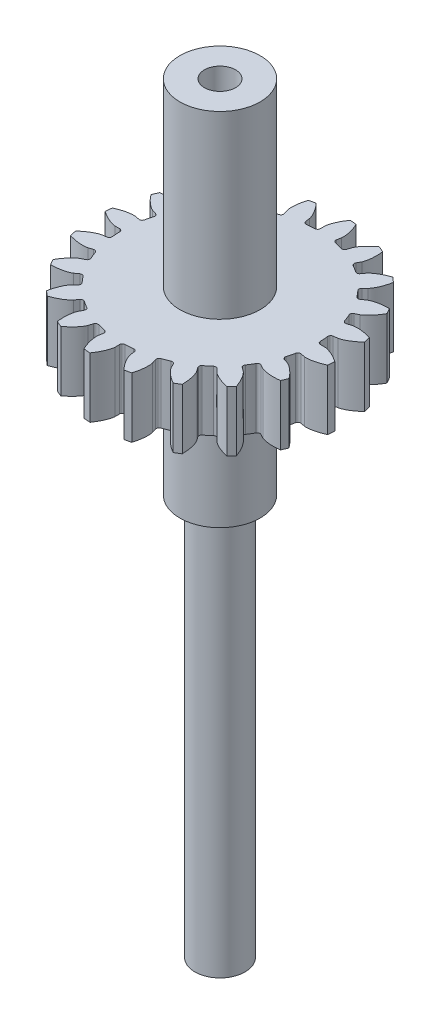
from build123d import *

# Parameters (mm, degrees)
SKETCH1_R            = 2.5
BEARINGSECTION_DEPTH = 2.5
SKETCH2_R            = 4
BOSS_EXTRUDE2_DEPTH  = 12
BOSS_EXTRUDE3_DEPTH  = 6
SKETCH7_R            = 4
BOSS_EXTRUDE4_DEPTH  = 17.95
SKETCH8_R            = 1.55
CUT_EXTRUDE1_DEPTH   = 18.95
SKETCH9_R            = 2.5
BOSS_EXTRUDE5_DEPTH  = 34.95
SKETCH10_R           = 1.55
CUT_EXTRUDE2_DEPTH   = 17


with BuildPart() as part:
    # Sketch1 → BearingSection (new body, symmetric)
    with BuildSketch(Plane(origin=(0, 0, 0), x_dir=(1, 0, 0), z_dir=(0, 1, 0))):
        Circle(SKETCH1_R)
    extrude(amount=BEARINGSECTION_DEPTH, both=True)

    # Sketch2 → Boss-Extrude2 (add)
    with BuildSketch(Plane(origin=(0, 2.5, 0), x_dir=(1, 0, 0), z_dir=(0, 1, 0))):
        Circle(SKETCH2_R)
    extrude(amount=BOSS_EXTRUDE2_DEPTH)

    # GearSketch → Boss-Extrude3 (add)
    with BuildSketch(Plane(origin=(0, 14.5, 0), x_dir=(1, 0, 0), z_dir=(0, 1, 0))):
        with BuildLine():
            Line((-9.850675874, 1.771154304), (-10.289089687, 1.849981232))
            add(Edge.make_bspline(
                [(-10.289089687, 1.849981232), (-10.296725387, 1.851187956), (-10.318214598, 1.854071384), (-10.359105487, 1.857540428), (-10.426058487, 1.860369506), (-10.511594622, 1.8598097), (-10.622203614, 1.854298135), (-10.752376809, 1.841657203), (-10.89505139, 1.821337826), (-11.049607754, 1.792328646), (-11.203014554, 1.757310247), (-11.355131771, 1.716760623), (-11.505723573, 1.671321215), (-11.686834397, 1.610374754), (-11.868284774, 1.541863752), (-12.011218437, 1.481845381), (-12.116563281, 1.434584042), (-12.155203392, 1.416840409)],
                knots=[0, 0, 0, 0, 0, 0.005376748, 0.015083688, 0.02853182, 0.046610139, 0.064854849, 0.092110525, 0.119476175, 0.146842495, 0.174208853, 0.201574955, 0.228941013, 0.256307345, 0.307035032, 0.336624535, 0.336624535, 0.336624535, 0.336624535, 0.336624535], degree=4))
            ThreePointArc((-12.155203392, 1.416840409), (-12.189120016, 1.087087613), (-12.21409259, 0.756537141))
            add(Edge.make_bspline(
                [(-12.21409259, 0.756537141), (-12.179202273, 0.732235691), (-12.083883515, 0.667078153), (-11.953826699, 0.582713105), (-11.787363934, 0.483173443), (-11.619896721, 0.391139023), (-11.479722698, 0.319767641), (-11.337182026, 0.252938931), (-11.192393304, 0.191325941), (-11.045409754, 0.135423901), (-10.908582693, 0.090177148), (-10.782700919, 0.054699934), (-10.674812946, 0.0297017), (-10.590725843, 0.014014033), (-10.524328883, 0.004950284), (-10.48346946, 0.00112842), (-10.461809141, 0.000163554), (-10.454080406, 0)],
                knots=[0, 0, 0, 0, 0, 0.029589503, 0.08031719, 0.107683522, 0.13504958, 0.162415682, 0.18978204, 0.21714836, 0.24451401, 0.271769686, 0.290014396, 0.308092715, 0.321540847, 0.331247787, 0.336624535, 0.336624535, 0.336624535, 0.336624535, 0.336624535], degree=4))
            Line((-10.454080406, 0), (-10.008636407, 0))
            ThreePointArc((-10.008636407, 0), (-9.814723016, -0.07874819), (-9.730618729, -0.270399306))
            ThreePointArc((-9.730618729, -0.270399306), (-9.7117918, -0.662688973), (-9.677156173, -1.053899925))
            ThreePointArc((-9.677156173, -1.053899925), (-9.734447291, -1.255199227), (-9.915866259, -1.359558409))
            Line((-9.915866259, -1.359558409), (-10.357181433, -1.420066864))
            add(Edge.make_bspline(
                [(-10.357181433, -1.420066864), (-10.364816314, -1.421278762), (-10.386144797, -1.425176991), (-10.426106336, -1.434513714), (-10.490656656, -1.452512715), (-10.571833365, -1.479477242), (-10.675325601, -1.51889911), (-10.795221403, -1.57114708), (-10.92463396, -1.634560827), (-11.062661468, -1.709910739), (-11.197738724, -1.790620524), (-11.329880272, -1.876192313), (-11.459060037, -1.965943185), (-11.612473175, -2.079873036), (-11.763871674, -2.201102121), (-11.881262969, -2.302351914), (-11.966847312, -2.379853466), (-11.998113158, -2.408669115)],
                knots=[0, 0, 0, 0, 0, 0.005376748, 0.015083688, 0.02853182, 0.046610139, 0.064854849, 0.092110525, 0.119476175, 0.146842495, 0.174208853, 0.201574955, 0.228941013, 0.256307345, 0.307035032, 0.336624535, 0.336624535, 0.336624535, 0.336624535, 0.336624535], degree=4))
            ThreePointArc((-11.998113158, -2.408669115), (-11.928470566, -2.732763473), (-11.850075182, -3.054852604))
            add(Edge.make_bspline(
                [(-11.850075182, -3.054852604), (-11.809382957, -3.067182954), (-11.698594645, -3.09969634), (-11.548833029, -3.139742502), (-11.359758084, -3.182970523), (-11.172047101, -3.218750243), (-11.016678713, -3.243312305), (-10.860463271, -3.262822696), (-10.703721552, -3.276677955), (-10.546657208, -3.28442354), (-10.402544925, -3.285173872), (-10.271861181, -3.280015101), (-10.161528742, -3.270450617), (-10.076709399, -3.259386131), (-10.010761285, -3.247488479), (-9.970720645, -3.238497032), (-9.949822297, -3.232721268), (-9.942421292, -3.230488506)],
                knots=[0, 0, 0, 0, 0, 0.029589503, 0.08031719, 0.107683522, 0.13504958, 0.162415682, 0.18978204, 0.21714836, 0.24451401, 0.271769686, 0.290014396, 0.308092715, 0.321540847, 0.331247787, 0.336624535, 0.336624535, 0.336624535, 0.336624535, 0.336624535], degree=4))
            Line((-9.942421292, -3.230488506), (-9.518778874, -3.09283874))
            ThreePointArc((-9.518778874, -3.09283874), (-9.310021751, -3.107810187), (-9.170810369, -3.264091575))
            ThreePointArc((-9.170810369, -3.264091575), (-9.031680722, -3.631363378), (-8.87784945, -3.992724106))
            ThreePointArc((-8.87784945, -3.992724106), (-8.870131636, -4.201875048), (-9.010422567, -4.357188072))
            Line((-9.010422567, -4.357188072), (-9.411440098, -4.551108922))
            add(Edge.make_bspline(
                [(-9.411440098, -4.551108922), (-9.418326804, -4.554620813), (-9.437406778, -4.564919113), (-9.472527255, -4.586147658), (-9.52835626, -4.623212872), (-9.597227401, -4.673942643), (-9.683472338, -4.743415927), (-9.781354512, -4.83015654), (-9.884837242, -4.930457276), (-9.992824799, -5.044772147), (-10.096350209, -5.163272882), (-10.195581152, -5.285490473), (-10.290703865, -5.410767368), (-10.401402169, -5.566528362), (-10.507928851, -5.728608782), (-10.5882867, -5.861178963), (-10.64573295, -5.961334335), (-10.666564012, -5.998401323)],
                knots=[0, 0, 0, 0, 0, 0.005376748, 0.015083688, 0.02853182, 0.046610139, 0.064854849, 0.092110525, 0.119476175, 0.146842495, 0.174208853, 0.201574955, 0.228941013, 0.256307345, 0.307035032, 0.336624535, 0.336624535, 0.336624535, 0.336624535, 0.336624535], degree=4))
            ThreePointArc((-10.666564012, -5.998401323), (-10.500179306, -6.285112631), (-10.326089851, -6.567212091))
            add(Edge.make_bspline(
                [(-10.326089851, -6.567212091), (-10.283578957, -6.566364362), (-10.168165822, -6.563050958), (-10.013359117, -6.554858237), (-9.820179965, -6.537543157), (-9.63059967, -6.513565809), (-9.475245457, -6.488914246), (-9.320646701, -6.459196504), (-9.167294957, -6.423937784), (-9.015524373, -6.382768721), (-8.878233581, -6.338949185), (-8.755540103, -6.293659404), (-8.653563306, -6.25046844), (-8.576314431, -6.213734871), (-8.517270624, -6.182040443), (-8.481968222, -6.16111583), (-8.463877522, -6.149164808), (-8.457528709, -6.144754289)],
                knots=[0, 0, 0, 0, 0, 0.029589503, 0.08031719, 0.107683522, 0.13504958, 0.162415682, 0.18978204, 0.21714836, 0.24451401, 0.271769686, 0.290014396, 0.308092715, 0.321540847, 0.331247787, 0.336624535, 0.336624535, 0.336624535, 0.336624535, 0.336624535], degree=4))
            Line((-8.457528709, -6.144754289), (-8.097156944, -5.882928876))
            ThreePointArc((-8.097156944, -5.882928876), (-7.89399069, -5.832658068), (-7.713299194, -5.938271818))
            ThreePointArc((-7.713299194, -5.938271818), (-7.467485807, -6.244574634), (-7.209516967, -6.540712632))
            ThreePointArc((-7.209516967, -6.540712632), (-7.137545695, -6.737242062), (-7.222975935, -6.928305808))
            Line((-7.222975935, -6.928305808), (-7.544441433, -7.236656728))
            add(Edge.make_bspline(
                [(-7.544441433, -7.236656728), (-7.549905846, -7.242124844), (-7.564869629, -7.257815146), (-7.591711206, -7.288857516), (-7.633353964, -7.341360741), (-7.683177951, -7.410889973), (-7.743733335, -7.503614144), (-7.81002049, -7.616356625), (-7.877443783, -7.743726216), (-7.944820815, -7.885816109), (-8.00666059, -8.030508116), (-8.063267512, -8.177408), (-8.115021899, -8.325947942), (-8.172169448, -8.508293107), (-8.223396739, -8.695359302), (-8.258855156, -8.846272977), (-8.282540074, -8.959278265), (-8.290897262, -9.000968217)],
                knots=[0, 0, 0, 0, 0, 0.005376748, 0.015083688, 0.02853182, 0.046610139, 0.064854849, 0.092110525, 0.119476175, 0.146842495, 0.174208853, 0.201574955, 0.228941013, 0.256307345, 0.307035032, 0.336624535, 0.336624535, 0.336624535, 0.336624535, 0.336624535], degree=4))
            ThreePointArc((-8.290897262, -9.000968217), (-8.044057337, -9.222231173), (-7.791314899, -9.436727102))
            add(Edge.make_bspline(
                [(-7.791314899, -9.436727102), (-7.751146599, -9.422784276), (-7.642406083, -9.383968421), (-7.497707847, -9.328338778), (-7.31933421, -9.252175517), (-7.146442043, -9.170788171), (-7.006309158, -9.09933605), (-6.868460291, -9.023299154), (-6.73350966, -8.942377824), (-6.601889196, -8.856324029), (-6.484858876, -8.772223985), (-6.382165756, -8.691236474), (-6.2985268, -8.618646864), (-6.236410052, -8.559839948), (-6.190050171, -8.511451216), (-6.162941653, -8.480641684), (-6.149429443, -8.463685253), (-6.144754289, -8.457528709)],
                knots=[0, 0, 0, 0, 0, 0.029589503, 0.08031719, 0.107683522, 0.13504958, 0.162415682, 0.18978204, 0.21714836, 0.24451401, 0.271769686, 0.290014396, 0.308092715, 0.321540847, 0.331247787, 0.336624535, 0.336624535, 0.336624535, 0.336624535, 0.336624535], degree=4))
            Line((-6.144754289, -8.457528709), (-5.882928876, -8.097156944))
            ThreePointArc((-5.882928876, -8.097156944), (-5.70524082, -7.98656474), (-5.500756551, -8.031172642))
            ThreePointArc((-5.500756551, -8.031172642), (-5.172321352, -8.246523417), (-4.835466732, -8.448450634))
            ThreePointArc((-4.835466732, -8.448450634), (-4.706287051, -8.613120883), (-4.728494093, -8.8212327))
            Line((-4.728494093, -8.8212327), (-4.938940275, -9.213830153))
            add(Edge.make_bspline(
                [(-4.938940275, -9.213830153), (-4.9424475, -9.220719237), (-4.951830334, -9.240265664), (-4.96776557, -9.278083216), (-4.991145798, -9.34088507), (-5.017045511, -9.422407758), (-5.045983759, -9.529306328), (-5.074187247, -9.657014656), (-5.098951242, -9.798985279), (-5.119122415, -9.954941446), (-5.133223247, -10.111661263), (-5.141665068, -10.268863856), (-5.144985049, -10.426126721), (-5.142987842, -10.617206842), (-5.133901258, -10.810947469), (-5.120989326, -10.965432157), (-5.108594468, -11.080225614), (-5.103659722, -11.122457628)],
                knots=[0, 0, 0, 0, 0, 0.005376748, 0.015083688, 0.02853182, 0.046610139, 0.064854849, 0.092110525, 0.119476175, 0.146842495, 0.174208853, 0.201574955, 0.228941013, 0.256307345, 0.307035032, 0.336624535, 0.336624535, 0.336624535, 0.336624535, 0.336624535], degree=4))
            ThreePointArc((-5.103659722, -11.122457628), (-4.80052699, -11.256613473), (-4.493871759, -11.382509515))
            add(Edge.make_bspline(
                [(-4.493871759, -11.382509515), (-4.459978006, -11.356836412), (-4.368554389, -11.286317673), (-4.248128693, -11.188696524), (-4.102021026, -11.061140474), (-3.962740876, -10.93030989), (-3.851546503, -10.819051442), (-3.743941133, -10.704138414), (-3.640601522, -10.585475617), (-3.542015107, -10.462960635), (-3.456701001, -10.346812383), (-3.384060558, -10.238054763), (-3.326946607, -10.143172082), (-3.286042405, -10.068048251), (-3.256904479, -10.007701841), (-3.240643415, -9.970023242), (-3.233032365, -9.949721215), (-3.230488506, -9.942421292)],
                knots=[0, 0, 0, 0, 0, 0.029589503, 0.08031719, 0.107683522, 0.13504958, 0.162415682, 0.18978204, 0.21714836, 0.24451401, 0.271769686, 0.290014396, 0.308092715, 0.321540847, 0.331247787, 0.336624535, 0.336624535, 0.336624535, 0.336624535, 0.336624535], degree=4))
            Line((-3.230488506, -9.942421292), (-3.09283874, -9.518778874))
            ThreePointArc((-3.09283874, -9.518778874), (-2.958022227, -9.358690809), (-2.749761532, -9.337926331))
            ThreePointArc((-2.749761532, -9.337926331), (-2.370854046, -9.441245031), (-1.988087323, -9.529195424))
            ThreePointArc((-1.988087323, -9.529195424), (-1.81434424, -9.645887421), (-1.771154304, -9.850675874))
            Line((-1.771154304, -9.850675874), (-1.849981232, -10.289089687))
            add(Edge.make_bspline(
                [(-1.849981232, -10.289089687), (-1.851187956, -10.296725387), (-1.854071384, -10.318214598), (-1.857540428, -10.359105487), (-1.860369506, -10.426058487), (-1.8598097, -10.511594622), (-1.854298135, -10.622203614), (-1.841657203, -10.752376809), (-1.821337826, -10.89505139), (-1.792328646, -11.049607754), (-1.757310247, -11.203014554), (-1.716760623, -11.355131771), (-1.671321215, -11.505723573), (-1.610374754, -11.686834397), (-1.541863752, -11.868284774), (-1.481845381, -12.011218437), (-1.434584042, -12.116563281), (-1.416840409, -12.155203392)],
                knots=[0, 0, 0, 0, 0, 0.005376748, 0.015083688, 0.02853182, 0.046610139, 0.064854849, 0.092110525, 0.119476175, 0.146842495, 0.174208853, 0.201574955, 0.228941013, 0.256307345, 0.307035032, 0.336624535, 0.336624535, 0.336624535, 0.336624535, 0.336624535], degree=4))
            ThreePointArc((-1.416840409, -12.155203392), (-1.087087613, -12.189120016), (-0.756537141, -12.21409259))
            add(Edge.make_bspline(
                [(-0.756537141, -12.21409259), (-0.732235691, -12.179202273), (-0.667078153, -12.083883515), (-0.582713105, -11.953826699), (-0.483173443, -11.787363934), (-0.391139023, -11.619896721), (-0.319767641, -11.479722698), (-0.252938931, -11.337182026), (-0.191325941, -11.192393304), (-0.135423901, -11.045409754), (-0.090177148, -10.908582693), (-0.054699934, -10.782700919), (-0.0297017, -10.674812946), (-0.014014033, -10.590725843), (-0.004950284, -10.524328883), (-0.00112842, -10.48346946), (-0.000163554, -10.461809141), (0, -10.454080406)],
                knots=[0, 0, 0, 0, 0, 0.029589503, 0.08031719, 0.107683522, 0.13504958, 0.162415682, 0.18978204, 0.21714836, 0.24451401, 0.271769686, 0.290014396, 0.308092715, 0.321540847, 0.331247787, 0.336624535, 0.336624535, 0.336624535, 0.336624535, 0.336624535], degree=4))
            Line((0, -10.454080406), (0, -10.008636407))
            ThreePointArc((0, -10.008636407), (0.07874819, -9.814723016), (0.270399306, -9.730618729))
            ThreePointArc((0.270399306, -9.730618729), (0.662688973, -9.7117918), (1.053899925, -9.677156173))
            ThreePointArc((1.053899925, -9.677156173), (1.255199227, -9.734447291), (1.359558409, -9.915866259))
            Line((1.359558409, -9.915866259), (1.420066864, -10.357181433))
            add(Edge.make_bspline(
                [(1.420066864, -10.357181433), (1.421278762, -10.364816314), (1.425176991, -10.386144797), (1.434513714, -10.426106336), (1.452512715, -10.490656656), (1.479477242, -10.571833365), (1.51889911, -10.675325601), (1.57114708, -10.795221403), (1.634560827, -10.92463396), (1.709910739, -11.062661468), (1.790620524, -11.197738724), (1.876192313, -11.329880272), (1.965943185, -11.459060037), (2.079873036, -11.612473175), (2.201102121, -11.763871674), (2.302351914, -11.881262969), (2.379853466, -11.966847312), (2.408669115, -11.998113158)],
                knots=[0, 0, 0, 0, 0, 0.005376748, 0.015083688, 0.02853182, 0.046610139, 0.064854849, 0.092110525, 0.119476175, 0.146842495, 0.174208853, 0.201574955, 0.228941013, 0.256307345, 0.307035032, 0.336624535, 0.336624535, 0.336624535, 0.336624535, 0.336624535], degree=4))
            ThreePointArc((2.408669115, -11.998113158), (2.732763473, -11.928470566), (3.054852604, -11.850075182))
            add(Edge.make_bspline(
                [(3.054852604, -11.850075182), (3.067182954, -11.809382957), (3.09969634, -11.698594645), (3.139742502, -11.548833029), (3.182970523, -11.359758084), (3.218750243, -11.172047101), (3.243312305, -11.016678713), (3.262822696, -10.860463271), (3.276677955, -10.703721552), (3.28442354, -10.546657208), (3.285173872, -10.402544925), (3.280015101, -10.271861181), (3.270450617, -10.161528742), (3.259386131, -10.076709399), (3.247488479, -10.010761285), (3.238497032, -9.970720645), (3.232721268, -9.949822297), (3.230488506, -9.942421292)],
                knots=[0, 0, 0, 0, 0, 0.029589503, 0.08031719, 0.107683522, 0.13504958, 0.162415682, 0.18978204, 0.21714836, 0.24451401, 0.271769686, 0.290014396, 0.308092715, 0.321540847, 0.331247787, 0.336624535, 0.336624535, 0.336624535, 0.336624535, 0.336624535], degree=4))
            Line((3.230488506, -9.942421292), (3.09283874, -9.518778874))
            ThreePointArc((3.09283874, -9.518778874), (3.107810187, -9.310021751), (3.264091575, -9.170810369))
            ThreePointArc((3.264091575, -9.170810369), (3.631363378, -9.031680722), (3.992724106, -8.87784945))
            ThreePointArc((3.992724106, -8.87784945), (4.201875048, -8.870131636), (4.357188072, -9.010422567))
            Line((4.357188072, -9.010422567), (4.551108922, -9.411440098))
            add(Edge.make_bspline(
                [(4.551108922, -9.411440098), (4.554620813, -9.418326804), (4.564919113, -9.437406778), (4.586147658, -9.472527255), (4.623212872, -9.52835626), (4.673942643, -9.597227401), (4.743415927, -9.683472338), (4.83015654, -9.781354512), (4.930457276, -9.884837242), (5.044772147, -9.992824799), (5.163272882, -10.096350209), (5.285490473, -10.195581152), (5.410767368, -10.290703865), (5.566528362, -10.401402169), (5.728608782, -10.507928851), (5.861178963, -10.5882867), (5.961334335, -10.64573295), (5.998401323, -10.666564012)],
                knots=[0, 0, 0, 0, 0, 0.005376748, 0.015083688, 0.02853182, 0.046610139, 0.064854849, 0.092110525, 0.119476175, 0.146842495, 0.174208853, 0.201574955, 0.228941013, 0.256307345, 0.307035032, 0.336624535, 0.336624535, 0.336624535, 0.336624535, 0.336624535], degree=4))
            ThreePointArc((5.998401323, -10.666564012), (6.285112631, -10.500179306), (6.567212091, -10.326089851))
            add(Edge.make_bspline(
                [(6.567212091, -10.326089851), (6.566364362, -10.283578957), (6.563050958, -10.168165822), (6.554858237, -10.013359117), (6.537543157, -9.820179965), (6.513565809, -9.63059967), (6.488914246, -9.475245457), (6.459196504, -9.320646701), (6.423937784, -9.167294957), (6.382768721, -9.015524373), (6.338949185, -8.878233581), (6.293659404, -8.755540103), (6.25046844, -8.653563306), (6.213734871, -8.576314431), (6.182040443, -8.517270624), (6.16111583, -8.481968222), (6.149164808, -8.463877522), (6.144754289, -8.457528709)],
                knots=[0, 0, 0, 0, 0, 0.029589503, 0.08031719, 0.107683522, 0.13504958, 0.162415682, 0.18978204, 0.21714836, 0.24451401, 0.271769686, 0.290014396, 0.308092715, 0.321540847, 0.331247787, 0.336624535, 0.336624535, 0.336624535, 0.336624535, 0.336624535], degree=4))
            Line((6.144754289, -8.457528709), (5.882928876, -8.097156944))
            ThreePointArc((5.882928876, -8.097156944), (5.832658068, -7.89399069), (5.938271818, -7.713299194))
            ThreePointArc((5.938271818, -7.713299194), (6.244574634, -7.467485807), (6.540712632, -7.209516967))
            ThreePointArc((6.540712632, -7.209516967), (6.737242062, -7.137545695), (6.928305808, -7.222975935))
            Line((6.928305808, -7.222975935), (7.236656728, -7.544441433))
            add(Edge.make_bspline(
                [(7.236656728, -7.544441433), (7.242124844, -7.549905846), (7.257815146, -7.564869629), (7.288857516, -7.591711206), (7.341360741, -7.633353964), (7.410889973, -7.683177951), (7.503614144, -7.743733335), (7.616356625, -7.81002049), (7.743726216, -7.877443783), (7.885816109, -7.944820815), (8.030508116, -8.00666059), (8.177408, -8.063267512), (8.325947942, -8.115021899), (8.508293107, -8.172169448), (8.695359302, -8.223396739), (8.846272977, -8.258855156), (8.959278265, -8.282540074), (9.000968217, -8.290897262)],
                knots=[0, 0, 0, 0, 0, 0.005376748, 0.015083688, 0.02853182, 0.046610139, 0.064854849, 0.092110525, 0.119476175, 0.146842495, 0.174208853, 0.201574955, 0.228941013, 0.256307345, 0.307035032, 0.336624535, 0.336624535, 0.336624535, 0.336624535, 0.336624535], degree=4))
            ThreePointArc((9.000968217, -8.290897262), (9.222231173, -8.044057337), (9.436727102, -7.791314899))
            add(Edge.make_bspline(
                [(9.436727102, -7.791314899), (9.422784276, -7.751146599), (9.383968421, -7.642406083), (9.328338778, -7.497707847), (9.252175517, -7.31933421), (9.170788171, -7.146442043), (9.09933605, -7.006309158), (9.023299154, -6.868460291), (8.942377824, -6.73350966), (8.856324029, -6.601889196), (8.772223985, -6.484858876), (8.691236474, -6.382165756), (8.618646864, -6.2985268), (8.559839948, -6.236410052), (8.511451216, -6.190050171), (8.480641684, -6.162941653), (8.463685253, -6.149429443), (8.457528709, -6.144754289)],
                knots=[0, 0, 0, 0, 0, 0.029589503, 0.08031719, 0.107683522, 0.13504958, 0.162415682, 0.18978204, 0.21714836, 0.24451401, 0.271769686, 0.290014396, 0.308092715, 0.321540847, 0.331247787, 0.336624535, 0.336624535, 0.336624535, 0.336624535, 0.336624535], degree=4))
            Line((8.457528709, -6.144754289), (8.097156944, -5.882928876))
            ThreePointArc((8.097156944, -5.882928876), (7.98656474, -5.70524082), (8.031172642, -5.500756551))
            ThreePointArc((8.031172642, -5.500756551), (8.246523417, -5.172321352), (8.448450634, -4.835466732))
            ThreePointArc((8.448450634, -4.835466732), (8.613120883, -4.706287051), (8.8212327, -4.728494093))
            Line((8.8212327, -4.728494093), (9.213830153, -4.938940275))
            add(Edge.make_bspline(
                [(9.213830153, -4.938940275), (9.220719237, -4.9424475), (9.240265664, -4.951830334), (9.278083216, -4.96776557), (9.34088507, -4.991145798), (9.422407758, -5.017045511), (9.529306328, -5.045983759), (9.657014656, -5.074187247), (9.798985279, -5.098951242), (9.954941446, -5.119122415), (10.111661263, -5.133223247), (10.268863856, -5.141665068), (10.426126721, -5.144985049), (10.617206842, -5.142987842), (10.810947469, -5.133901258), (10.965432157, -5.120989326), (11.080225614, -5.108594468), (11.122457628, -5.103659722)],
                knots=[0, 0, 0, 0, 0, 0.005376748, 0.015083688, 0.02853182, 0.046610139, 0.064854849, 0.092110525, 0.119476175, 0.146842495, 0.174208853, 0.201574955, 0.228941013, 0.256307345, 0.307035032, 0.336624535, 0.336624535, 0.336624535, 0.336624535, 0.336624535], degree=4))
            ThreePointArc((11.122457628, -5.103659722), (11.256613473, -4.80052699), (11.382509515, -4.493871759))
            add(Edge.make_bspline(
                [(11.382509515, -4.493871759), (11.356836412, -4.459978006), (11.286317673, -4.368554389), (11.188696524, -4.248128693), (11.061140474, -4.102021026), (10.93030989, -3.962740876), (10.819051442, -3.851546503), (10.704138414, -3.743941133), (10.585475617, -3.640601522), (10.462960635, -3.542015107), (10.346812383, -3.456701001), (10.238054763, -3.384060558), (10.143172082, -3.326946607), (10.068048251, -3.286042405), (10.007701841, -3.256904479), (9.970023242, -3.240643415), (9.949721215, -3.233032365), (9.942421292, -3.230488506)],
                knots=[0, 0, 0, 0, 0, 0.029589503, 0.08031719, 0.107683522, 0.13504958, 0.162415682, 0.18978204, 0.21714836, 0.24451401, 0.271769686, 0.290014396, 0.308092715, 0.321540847, 0.331247787, 0.336624535, 0.336624535, 0.336624535, 0.336624535, 0.336624535], degree=4))
            Line((9.942421292, -3.230488506), (9.518778874, -3.09283874))
            ThreePointArc((9.518778874, -3.09283874), (9.358690809, -2.958022227), (9.337926331, -2.749761532))
            ThreePointArc((9.337926331, -2.749761532), (9.441245031, -2.370854046), (9.529195424, -1.988087323))
            ThreePointArc((9.529195424, -1.988087323), (9.645887421, -1.81434424), (9.850675874, -1.771154304))
            Line((9.850675874, -1.771154304), (10.289089687, -1.849981232))
            add(Edge.make_bspline(
                [(10.289089687, -1.849981232), (10.296725387, -1.851187956), (10.318214598, -1.854071384), (10.359105487, -1.857540428), (10.426058487, -1.860369506), (10.511594622, -1.8598097), (10.622203614, -1.854298135), (10.752376809, -1.841657203), (10.89505139, -1.821337826), (11.049607754, -1.792328646), (11.203014554, -1.757310247), (11.355131771, -1.716760623), (11.505723573, -1.671321215), (11.686834397, -1.610374754), (11.868284774, -1.541863752), (12.011218437, -1.481845381), (12.116563281, -1.434584042), (12.155203392, -1.416840409)],
                knots=[0, 0, 0, 0, 0, 0.005376748, 0.015083688, 0.02853182, 0.046610139, 0.064854849, 0.092110525, 0.119476175, 0.146842495, 0.174208853, 0.201574955, 0.228941013, 0.256307345, 0.307035032, 0.336624535, 0.336624535, 0.336624535, 0.336624535, 0.336624535], degree=4))
            ThreePointArc((12.155203392, -1.416840409), (12.189120016, -1.087087613), (12.21409259, -0.756537141))
            add(Edge.make_bspline(
                [(12.21409259, -0.756537141), (12.179202273, -0.732235691), (12.083883515, -0.667078153), (11.953826699, -0.582713105), (11.787363934, -0.483173443), (11.619896721, -0.391139023), (11.479722698, -0.319767641), (11.337182026, -0.252938931), (11.192393304, -0.191325941), (11.045409754, -0.135423901), (10.908582693, -0.090177148), (10.782700919, -0.054699934), (10.674812946, -0.0297017), (10.590725843, -0.014014033), (10.524328883, -0.004950284), (10.48346946, -0.00112842), (10.461809141, -0.000163554), (10.454080406, 0)],
                knots=[0, 0, 0, 0, 0, 0.029589503, 0.08031719, 0.107683522, 0.13504958, 0.162415682, 0.18978204, 0.21714836, 0.24451401, 0.271769686, 0.290014396, 0.308092715, 0.321540847, 0.331247787, 0.336624535, 0.336624535, 0.336624535, 0.336624535, 0.336624535], degree=4))
            Line((10.454080406, 0), (10.008636407, 0))
            ThreePointArc((10.008636407, 0), (9.814723016, 0.07874819), (9.730618729, 0.270399306))
            ThreePointArc((9.730618729, 0.270399306), (9.7117918, 0.662688973), (9.677156173, 1.053899925))
            ThreePointArc((9.677156173, 1.053899925), (9.734447291, 1.255199227), (9.915866259, 1.359558409))
            Line((9.915866259, 1.359558409), (10.357181433, 1.420066864))
            add(Edge.make_bspline(
                [(10.357181433, 1.420066864), (10.364816314, 1.421278762), (10.386144797, 1.425176991), (10.426106336, 1.434513714), (10.490656656, 1.452512715), (10.571833365, 1.479477242), (10.675325601, 1.51889911), (10.795221403, 1.57114708), (10.92463396, 1.634560827), (11.062661468, 1.709910739), (11.197738724, 1.790620524), (11.329880272, 1.876192313), (11.459060037, 1.965943185), (11.612473175, 2.079873036), (11.763871674, 2.201102121), (11.881262969, 2.302351914), (11.966847312, 2.379853466), (11.998113158, 2.408669115)],
                knots=[0, 0, 0, 0, 0, 0.005376748, 0.015083688, 0.02853182, 0.046610139, 0.064854849, 0.092110525, 0.119476175, 0.146842495, 0.174208853, 0.201574955, 0.228941013, 0.256307345, 0.307035032, 0.336624535, 0.336624535, 0.336624535, 0.336624535, 0.336624535], degree=4))
            ThreePointArc((11.998113158, 2.408669115), (11.928470566, 2.732763473), (11.850075182, 3.054852604))
            add(Edge.make_bspline(
                [(11.850075182, 3.054852604), (11.809382957, 3.067182954), (11.698594645, 3.09969634), (11.548833029, 3.139742502), (11.359758084, 3.182970523), (11.172047101, 3.218750243), (11.016678713, 3.243312305), (10.860463271, 3.262822696), (10.703721552, 3.276677955), (10.546657208, 3.28442354), (10.402544925, 3.285173872), (10.271861181, 3.280015101), (10.161528742, 3.270450617), (10.076709399, 3.259386131), (10.010761285, 3.247488479), (9.970720645, 3.238497032), (9.949822297, 3.232721268), (9.942421292, 3.230488506)],
                knots=[0, 0, 0, 0, 0, 0.029589503, 0.08031719, 0.107683522, 0.13504958, 0.162415682, 0.18978204, 0.21714836, 0.24451401, 0.271769686, 0.290014396, 0.308092715, 0.321540847, 0.331247787, 0.336624535, 0.336624535, 0.336624535, 0.336624535, 0.336624535], degree=4))
            Line((9.942421292, 3.230488506), (9.518778874, 3.09283874))
            ThreePointArc((9.518778874, 3.09283874), (9.310021751, 3.107810187), (9.170810369, 3.264091575))
            ThreePointArc((9.170810369, 3.264091575), (9.031680722, 3.631363378), (8.87784945, 3.992724106))
            ThreePointArc((8.87784945, 3.992724106), (8.870131636, 4.201875048), (9.010422567, 4.357188072))
            Line((9.010422567, 4.357188072), (9.411440098, 4.551108922))
            add(Edge.make_bspline(
                [(9.411440098, 4.551108922), (9.418326804, 4.554620813), (9.437406778, 4.564919113), (9.472527255, 4.586147658), (9.52835626, 4.623212872), (9.597227401, 4.673942643), (9.683472338, 4.743415927), (9.781354512, 4.83015654), (9.884837242, 4.930457276), (9.992824799, 5.044772147), (10.096350209, 5.163272882), (10.195581152, 5.285490473), (10.290703865, 5.410767368), (10.401402169, 5.566528362), (10.507928851, 5.728608782), (10.5882867, 5.861178963), (10.64573295, 5.961334335), (10.666564012, 5.998401323)],
                knots=[0, 0, 0, 0, 0, 0.005376748, 0.015083688, 0.02853182, 0.046610139, 0.064854849, 0.092110525, 0.119476175, 0.146842495, 0.174208853, 0.201574955, 0.228941013, 0.256307345, 0.307035032, 0.336624535, 0.336624535, 0.336624535, 0.336624535, 0.336624535], degree=4))
            ThreePointArc((10.666564012, 5.998401323), (10.500179306, 6.285112631), (10.326089851, 6.567212091))
            add(Edge.make_bspline(
                [(10.326089851, 6.567212091), (10.283578957, 6.566364362), (10.168165822, 6.563050958), (10.013359117, 6.554858237), (9.820179965, 6.537543157), (9.63059967, 6.513565809), (9.475245457, 6.488914246), (9.320646701, 6.459196504), (9.167294957, 6.423937784), (9.015524373, 6.382768721), (8.878233581, 6.338949185), (8.755540103, 6.293659404), (8.653563306, 6.25046844), (8.576314431, 6.213734871), (8.517270624, 6.182040443), (8.481968222, 6.16111583), (8.463877522, 6.149164808), (8.457528709, 6.144754289)],
                knots=[0, 0, 0, 0, 0, 0.029589503, 0.08031719, 0.107683522, 0.13504958, 0.162415682, 0.18978204, 0.21714836, 0.24451401, 0.271769686, 0.290014396, 0.308092715, 0.321540847, 0.331247787, 0.336624535, 0.336624535, 0.336624535, 0.336624535, 0.336624535], degree=4))
            Line((8.457528709, 6.144754289), (8.097156944, 5.882928876))
            ThreePointArc((8.097156944, 5.882928876), (7.89399069, 5.832658068), (7.713299194, 5.938271818))
            ThreePointArc((7.713299194, 5.938271818), (7.467485807, 6.244574634), (7.209516967, 6.540712632))
            ThreePointArc((7.209516967, 6.540712632), (7.137545695, 6.737242062), (7.222975935, 6.928305808))
            Line((7.222975935, 6.928305808), (7.544441433, 7.236656728))
            add(Edge.make_bspline(
                [(7.544441433, 7.236656728), (7.549905846, 7.242124844), (7.564869629, 7.257815146), (7.591711206, 7.288857516), (7.633353964, 7.341360741), (7.683177951, 7.410889973), (7.743733335, 7.503614144), (7.81002049, 7.616356625), (7.877443783, 7.743726216), (7.944820815, 7.885816109), (8.00666059, 8.030508116), (8.063267512, 8.177408), (8.115021899, 8.325947942), (8.172169448, 8.508293107), (8.223396739, 8.695359302), (8.258855156, 8.846272977), (8.282540074, 8.959278265), (8.290897262, 9.000968217)],
                knots=[0, 0, 0, 0, 0, 0.005376748, 0.015083688, 0.02853182, 0.046610139, 0.064854849, 0.092110525, 0.119476175, 0.146842495, 0.174208853, 0.201574955, 0.228941013, 0.256307345, 0.307035032, 0.336624535, 0.336624535, 0.336624535, 0.336624535, 0.336624535], degree=4))
            ThreePointArc((8.290897262, 9.000968217), (8.044057337, 9.222231173), (7.791314899, 9.436727102))
            add(Edge.make_bspline(
                [(7.791314899, 9.436727102), (7.751146599, 9.422784276), (7.642406083, 9.383968421), (7.497707847, 9.328338778), (7.31933421, 9.252175517), (7.146442043, 9.170788171), (7.006309158, 9.09933605), (6.868460291, 9.023299154), (6.73350966, 8.942377824), (6.601889196, 8.856324029), (6.484858876, 8.772223985), (6.382165756, 8.691236474), (6.2985268, 8.618646864), (6.236410052, 8.559839948), (6.190050171, 8.511451216), (6.162941653, 8.480641684), (6.149429443, 8.463685253), (6.144754289, 8.457528709)],
                knots=[0, 0, 0, 0, 0, 0.029589503, 0.08031719, 0.107683522, 0.13504958, 0.162415682, 0.18978204, 0.21714836, 0.24451401, 0.271769686, 0.290014396, 0.308092715, 0.321540847, 0.331247787, 0.336624535, 0.336624535, 0.336624535, 0.336624535, 0.336624535], degree=4))
            Line((6.144754289, 8.457528709), (5.882928876, 8.097156944))
            ThreePointArc((5.882928876, 8.097156944), (5.70524082, 7.98656474), (5.500756551, 8.031172642))
            ThreePointArc((5.500756551, 8.031172642), (5.172321352, 8.246523417), (4.835466732, 8.448450634))
            ThreePointArc((4.835466732, 8.448450634), (4.706287051, 8.613120883), (4.728494093, 8.8212327))
            Line((4.728494093, 8.8212327), (4.938940275, 9.213830153))
            add(Edge.make_bspline(
                [(4.938940275, 9.213830153), (4.9424475, 9.220719237), (4.951830334, 9.240265664), (4.96776557, 9.278083216), (4.991145798, 9.34088507), (5.017045511, 9.422407758), (5.045983759, 9.529306328), (5.074187247, 9.657014656), (5.098951242, 9.798985279), (5.119122415, 9.954941446), (5.133223247, 10.111661263), (5.141665068, 10.268863856), (5.144985049, 10.426126721), (5.142987842, 10.617206842), (5.133901258, 10.810947469), (5.120989326, 10.965432157), (5.108594468, 11.080225614), (5.103659722, 11.122457628)],
                knots=[0, 0, 0, 0, 0, 0.005376748, 0.015083688, 0.02853182, 0.046610139, 0.064854849, 0.092110525, 0.119476175, 0.146842495, 0.174208853, 0.201574955, 0.228941013, 0.256307345, 0.307035032, 0.336624535, 0.336624535, 0.336624535, 0.336624535, 0.336624535], degree=4))
            ThreePointArc((5.103659722, 11.122457628), (4.80052699, 11.256613473), (4.493871759, 11.382509515))
            add(Edge.make_bspline(
                [(4.493871759, 11.382509515), (4.459978006, 11.356836412), (4.368554389, 11.286317673), (4.248128693, 11.188696524), (4.102021026, 11.061140474), (3.962740876, 10.93030989), (3.851546503, 10.819051442), (3.743941133, 10.704138414), (3.640601522, 10.585475617), (3.542015107, 10.462960635), (3.456701001, 10.346812383), (3.384060558, 10.238054763), (3.326946607, 10.143172082), (3.286042405, 10.068048251), (3.256904479, 10.007701841), (3.240643415, 9.970023242), (3.233032365, 9.949721215), (3.230488506, 9.942421292)],
                knots=[0, 0, 0, 0, 0, 0.029589503, 0.08031719, 0.107683522, 0.13504958, 0.162415682, 0.18978204, 0.21714836, 0.24451401, 0.271769686, 0.290014396, 0.308092715, 0.321540847, 0.331247787, 0.336624535, 0.336624535, 0.336624535, 0.336624535, 0.336624535], degree=4))
            Line((3.230488506, 9.942421292), (3.09283874, 9.518778874))
            ThreePointArc((3.09283874, 9.518778874), (2.958022227, 9.358690809), (2.749761532, 9.337926331))
            ThreePointArc((2.749761532, 9.337926331), (2.370854046, 9.441245031), (1.988087323, 9.529195424))
            ThreePointArc((1.988087323, 9.529195424), (1.81434424, 9.645887421), (1.771154304, 9.850675874))
            Line((1.771154304, 9.850675874), (1.849981232, 10.289089687))
            add(Edge.make_bspline(
                [(1.849981232, 10.289089687), (1.851187956, 10.296725387), (1.854071384, 10.318214598), (1.857540428, 10.359105487), (1.860369506, 10.426058487), (1.8598097, 10.511594622), (1.854298135, 10.622203614), (1.841657203, 10.752376809), (1.821337826, 10.89505139), (1.792328646, 11.049607754), (1.757310247, 11.203014554), (1.716760623, 11.355131771), (1.671321215, 11.505723573), (1.610374754, 11.686834397), (1.541863752, 11.868284774), (1.481845381, 12.011218437), (1.434584042, 12.116563281), (1.416840409, 12.155203392)],
                knots=[0, 0, 0, 0, 0, 0.005376748, 0.015083688, 0.02853182, 0.046610139, 0.064854849, 0.092110525, 0.119476175, 0.146842495, 0.174208853, 0.201574955, 0.228941013, 0.256307345, 0.307035032, 0.336624535, 0.336624535, 0.336624535, 0.336624535, 0.336624535], degree=4))
            ThreePointArc((1.416840409, 12.155203392), (1.087087613, 12.189120016), (0.756537141, 12.21409259))
            add(Edge.make_bspline(
                [(0.756537141, 12.21409259), (0.732235691, 12.179202273), (0.667078153, 12.083883515), (0.582713105, 11.953826699), (0.483173443, 11.787363934), (0.391139023, 11.619896721), (0.319767641, 11.479722698), (0.252938931, 11.337182026), (0.191325941, 11.192393304), (0.135423901, 11.045409754), (0.090177148, 10.908582693), (0.054699934, 10.782700919), (0.0297017, 10.674812946), (0.014014033, 10.590725843), (0.004950284, 10.524328883), (0.00112842, 10.48346946), (0.000163554, 10.461809141), (0, 10.454080406)],
                knots=[0, 0, 0, 0, 0, 0.029589503, 0.08031719, 0.107683522, 0.13504958, 0.162415682, 0.18978204, 0.21714836, 0.24451401, 0.271769686, 0.290014396, 0.308092715, 0.321540847, 0.331247787, 0.336624535, 0.336624535, 0.336624535, 0.336624535, 0.336624535], degree=4))
            Line((0, 10.454080406), (0, 10.008636407))
            ThreePointArc((0, 10.008636407), (-0.07874819, 9.814723016), (-0.270399306, 9.730618729))
            ThreePointArc((-0.270399306, 9.730618729), (-0.662688973, 9.7117918), (-1.053899925, 9.677156173))
            ThreePointArc((-1.053899925, 9.677156173), (-1.255199227, 9.734447291), (-1.359558409, 9.915866259))
            Line((-1.359558409, 9.915866259), (-1.420066864, 10.357181433))
            add(Edge.make_bspline(
                [(-1.420066864, 10.357181433), (-1.421278762, 10.364816314), (-1.425176991, 10.386144797), (-1.434513714, 10.426106336), (-1.452512715, 10.490656656), (-1.479477242, 10.571833365), (-1.51889911, 10.675325601), (-1.57114708, 10.795221403), (-1.634560827, 10.92463396), (-1.709910739, 11.062661468), (-1.790620524, 11.197738724), (-1.876192313, 11.329880272), (-1.965943185, 11.459060037), (-2.079873036, 11.612473175), (-2.201102121, 11.763871674), (-2.302351914, 11.881262969), (-2.379853466, 11.966847312), (-2.408669115, 11.998113158)],
                knots=[0, 0, 0, 0, 0, 0.005376748, 0.015083688, 0.02853182, 0.046610139, 0.064854849, 0.092110525, 0.119476175, 0.146842495, 0.174208853, 0.201574955, 0.228941013, 0.256307345, 0.307035032, 0.336624535, 0.336624535, 0.336624535, 0.336624535, 0.336624535], degree=4))
            ThreePointArc((-2.408669115, 11.998113158), (-2.732763473, 11.928470566), (-3.054852604, 11.850075182))
            add(Edge.make_bspline(
                [(-3.054852604, 11.850075182), (-3.067182954, 11.809382957), (-3.09969634, 11.698594645), (-3.139742502, 11.548833029), (-3.182970523, 11.359758084), (-3.218750243, 11.172047101), (-3.243312305, 11.016678713), (-3.262822696, 10.860463271), (-3.276677955, 10.703721552), (-3.28442354, 10.546657208), (-3.285173872, 10.402544925), (-3.280015101, 10.271861181), (-3.270450617, 10.161528742), (-3.259386131, 10.076709399), (-3.247488479, 10.010761285), (-3.238497032, 9.970720645), (-3.232721268, 9.949822297), (-3.230488506, 9.942421292)],
                knots=[0, 0, 0, 0, 0, 0.029589503, 0.08031719, 0.107683522, 0.13504958, 0.162415682, 0.18978204, 0.21714836, 0.24451401, 0.271769686, 0.290014396, 0.308092715, 0.321540847, 0.331247787, 0.336624535, 0.336624535, 0.336624535, 0.336624535, 0.336624535], degree=4))
            Line((-3.230488506, 9.942421292), (-3.09283874, 9.518778874))
            ThreePointArc((-3.09283874, 9.518778874), (-3.107810187, 9.310021751), (-3.264091575, 9.170810369))
            ThreePointArc((-3.264091575, 9.170810369), (-3.631363378, 9.031680722), (-3.992724106, 8.87784945))
            ThreePointArc((-3.992724106, 8.87784945), (-4.201875048, 8.870131636), (-4.357188072, 9.010422567))
            Line((-4.357188072, 9.010422567), (-4.551108922, 9.411440098))
            add(Edge.make_bspline(
                [(-4.551108922, 9.411440098), (-4.554620813, 9.418326804), (-4.564919113, 9.437406778), (-4.586147658, 9.472527255), (-4.623212872, 9.52835626), (-4.673942643, 9.597227401), (-4.743415927, 9.683472338), (-4.83015654, 9.781354512), (-4.930457276, 9.884837242), (-5.044772147, 9.992824799), (-5.163272882, 10.096350209), (-5.285490473, 10.195581152), (-5.410767368, 10.290703865), (-5.566528362, 10.401402169), (-5.728608782, 10.507928851), (-5.861178963, 10.5882867), (-5.961334335, 10.64573295), (-5.998401323, 10.666564012)],
                knots=[0, 0, 0, 0, 0, 0.005376748, 0.015083688, 0.02853182, 0.046610139, 0.064854849, 0.092110525, 0.119476175, 0.146842495, 0.174208853, 0.201574955, 0.228941013, 0.256307345, 0.307035032, 0.336624535, 0.336624535, 0.336624535, 0.336624535, 0.336624535], degree=4))
            ThreePointArc((-5.998401323, 10.666564012), (-6.285112631, 10.500179306), (-6.567212091, 10.326089851))
            add(Edge.make_bspline(
                [(-6.567212091, 10.326089851), (-6.566364362, 10.283578957), (-6.563050958, 10.168165822), (-6.554858237, 10.013359117), (-6.537543157, 9.820179965), (-6.513565809, 9.63059967), (-6.488914246, 9.475245457), (-6.459196504, 9.320646701), (-6.423937784, 9.167294957), (-6.382768721, 9.015524373), (-6.338949185, 8.878233581), (-6.293659404, 8.755540103), (-6.25046844, 8.653563306), (-6.213734871, 8.576314431), (-6.182040443, 8.517270624), (-6.16111583, 8.481968222), (-6.149164808, 8.463877522), (-6.144754289, 8.457528709)],
                knots=[0, 0, 0, 0, 0, 0.029589503, 0.08031719, 0.107683522, 0.13504958, 0.162415682, 0.18978204, 0.21714836, 0.24451401, 0.271769686, 0.290014396, 0.308092715, 0.321540847, 0.331247787, 0.336624535, 0.336624535, 0.336624535, 0.336624535, 0.336624535], degree=4))
            Line((-6.144754289, 8.457528709), (-5.882928876, 8.097156944))
            ThreePointArc((-5.882928876, 8.097156944), (-5.832658068, 7.89399069), (-5.938271818, 7.713299194))
            ThreePointArc((-5.938271818, 7.713299194), (-6.244574634, 7.467485807), (-6.540712632, 7.209516967))
            ThreePointArc((-6.540712632, 7.209516967), (-6.737242062, 7.137545695), (-6.928305808, 7.222975935))
            Line((-6.928305808, 7.222975935), (-7.236656728, 7.544441433))
            add(Edge.make_bspline(
                [(-7.236656728, 7.544441433), (-7.242124844, 7.549905846), (-7.257815146, 7.564869629), (-7.288857516, 7.591711206), (-7.341360741, 7.633353964), (-7.410889973, 7.683177951), (-7.503614144, 7.743733335), (-7.616356625, 7.81002049), (-7.743726216, 7.877443783), (-7.885816109, 7.944820815), (-8.030508116, 8.00666059), (-8.177408, 8.063267512), (-8.325947942, 8.115021899), (-8.508293107, 8.172169448), (-8.695359302, 8.223396739), (-8.846272977, 8.258855156), (-8.959278265, 8.282540074), (-9.000968217, 8.290897262)],
                knots=[0, 0, 0, 0, 0, 0.005376748, 0.015083688, 0.02853182, 0.046610139, 0.064854849, 0.092110525, 0.119476175, 0.146842495, 0.174208853, 0.201574955, 0.228941013, 0.256307345, 0.307035032, 0.336624535, 0.336624535, 0.336624535, 0.336624535, 0.336624535], degree=4))
            ThreePointArc((-9.000968217, 8.290897262), (-9.222231173, 8.044057337), (-9.436727102, 7.791314899))
            add(Edge.make_bspline(
                [(-9.436727102, 7.791314899), (-9.422784276, 7.751146599), (-9.383968421, 7.642406083), (-9.328338778, 7.497707847), (-9.252175517, 7.31933421), (-9.170788171, 7.146442043), (-9.09933605, 7.006309158), (-9.023299154, 6.868460291), (-8.942377824, 6.73350966), (-8.856324029, 6.601889196), (-8.772223985, 6.484858876), (-8.691236474, 6.382165756), (-8.618646864, 6.2985268), (-8.559839948, 6.236410052), (-8.511451216, 6.190050171), (-8.480641684, 6.162941653), (-8.463685253, 6.149429443), (-8.457528709, 6.144754289)],
                knots=[0, 0, 0, 0, 0, 0.029589503, 0.08031719, 0.107683522, 0.13504958, 0.162415682, 0.18978204, 0.21714836, 0.24451401, 0.271769686, 0.290014396, 0.308092715, 0.321540847, 0.331247787, 0.336624535, 0.336624535, 0.336624535, 0.336624535, 0.336624535], degree=4))
            Line((-8.457528709, 6.144754289), (-8.097156944, 5.882928876))
            ThreePointArc((-8.097156944, 5.882928876), (-7.98656474, 5.70524082), (-8.031172642, 5.500756551))
            ThreePointArc((-8.031172642, 5.500756551), (-8.246523417, 5.172321352), (-8.448450634, 4.835466732))
            ThreePointArc((-8.448450634, 4.835466732), (-8.613120883, 4.706287051), (-8.8212327, 4.728494093))
            Line((-8.8212327, 4.728494093), (-9.213830153, 4.938940275))
            add(Edge.make_bspline(
                [(-9.213830153, 4.938940275), (-9.220719237, 4.9424475), (-9.240265664, 4.951830334), (-9.278083216, 4.96776557), (-9.34088507, 4.991145798), (-9.422407758, 5.017045511), (-9.529306328, 5.045983759), (-9.657014656, 5.074187247), (-9.798985279, 5.098951242), (-9.954941446, 5.119122415), (-10.111661263, 5.133223247), (-10.268863856, 5.141665068), (-10.426126721, 5.144985049), (-10.617206842, 5.142987842), (-10.810947469, 5.133901258), (-10.965432157, 5.120989326), (-11.080225614, 5.108594468), (-11.122457628, 5.103659722)],
                knots=[0, 0, 0, 0, 0, 0.005376748, 0.015083688, 0.02853182, 0.046610139, 0.064854849, 0.092110525, 0.119476175, 0.146842495, 0.174208853, 0.201574955, 0.228941013, 0.256307345, 0.307035032, 0.336624535, 0.336624535, 0.336624535, 0.336624535, 0.336624535], degree=4))
            ThreePointArc((-11.122457628, 5.103659722), (-11.256613473, 4.80052699), (-11.382509515, 4.493871759))
            add(Edge.make_bspline(
                [(-11.382509515, 4.493871759), (-11.356836412, 4.459978006), (-11.286317673, 4.368554389), (-11.188696524, 4.248128693), (-11.061140474, 4.102021026), (-10.93030989, 3.962740876), (-10.819051442, 3.851546503), (-10.704138414, 3.743941133), (-10.585475617, 3.640601522), (-10.462960635, 3.542015107), (-10.346812383, 3.456701001), (-10.238054763, 3.384060558), (-10.143172082, 3.326946607), (-10.068048251, 3.286042405), (-10.007701841, 3.256904479), (-9.970023242, 3.240643415), (-9.949721215, 3.233032365), (-9.942421292, 3.230488506)],
                knots=[0, 0, 0, 0, 0, 0.029589503, 0.08031719, 0.107683522, 0.13504958, 0.162415682, 0.18978204, 0.21714836, 0.24451401, 0.271769686, 0.290014396, 0.308092715, 0.321540847, 0.331247787, 0.336624535, 0.336624535, 0.336624535, 0.336624535, 0.336624535], degree=4))
            Line((-9.942421292, 3.230488506), (-9.518778874, 3.09283874))
            ThreePointArc((-9.518778874, 3.09283874), (-9.358690809, 2.958022227), (-9.337926331, 2.749761532))
            ThreePointArc((-9.337926331, 2.749761532), (-9.441245031, 2.370854046), (-9.529195424, 1.988087323))
            ThreePointArc((-9.529195424, 1.988087323), (-9.645887421, 1.81434424), (-9.850675874, 1.771154304))
        make_face()
    extrude(amount=BOSS_EXTRUDE3_DEPTH)

    # Sketch7 → Boss-Extrude4 (add)
    with BuildSketch(Plane(origin=(0, 20.5, 0), x_dir=(1, 0, 0), z_dir=(0, 1, 0))):
        Circle(SKETCH7_R)
    extrude(amount=BOSS_EXTRUDE4_DEPTH)

    # Sketch8 → Cut-Extrude1 (cut)
    with BuildSketch(Plane(origin=(0, 38.45, 0), x_dir=(1, 0, 0), z_dir=(0, 1, 0))):
        Circle(SKETCH8_R)
    extrude(amount=-CUT_EXTRUDE1_DEPTH, mode=Mode.SUBTRACT)

    # Sketch9 → Boss-Extrude5 (add)
    with BuildSketch(Plane.XZ.offset(2.5)):
        Circle(SKETCH9_R)
    extrude(amount=BOSS_EXTRUDE5_DEPTH)

    # Sketch10 → Cut-Extrude2 (cut)
    with BuildSketch(Plane.XZ.offset(37.45)):
        Circle(SKETCH10_R)
    extrude(amount=-CUT_EXTRUDE2_DEPTH, mode=Mode.SUBTRACT)


solid = part.part
